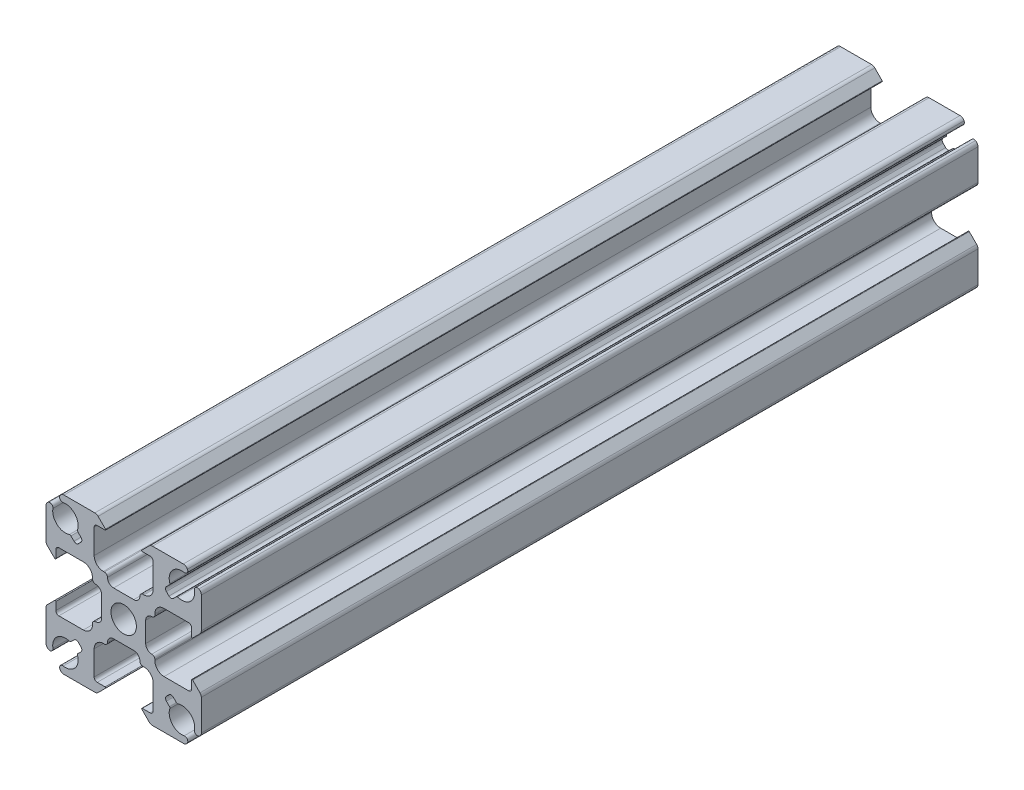
from build123d import *

# Parameters (mm, degrees)
SKETCH1_R           = 2.08
BOSS_EXTRUDE1_DEPTH = 63.5
SKETCH3_W           = 2.5
SKETCH3_H           = 16.3


with BuildPart() as part:
    # Sketch1 → Boss-Extrude1 (new body, symmetric)
    with BuildSketch(Plane(origin=(0, 0, 0), x_dir=(-1, 0, 0), z_dir=(0, 0, -1))):
        with BuildLine():
            Line((-7.48853247, 8.61990332), (-6.985643798, 8.117014648))
            ThreePointArc((-6.985643798, 8.117014648), (-6.839197188, 7.763461257), (-6.985643798, 7.409907866))
            Line((-6.985643798, 7.409907866), (-7.409907866, 6.985643798))
            ThreePointArc((-7.409907866, 6.985643798), (-7.763461257, 6.839197188), (-8.117014648, 6.985643798))
            Line((-8.117014648, 6.985643798), (-8.61990332, 7.48853247))
            ThreePointArc((-8.61990332, 7.48853247), (-8.738774884, 7.554957329), (-8.874825936, 7.549228331))
            ThreePointArc((-8.874825936, 7.549228331), (-10.889377278, 7.955008076), (-11.572136222, 9.893284252))
            ThreePointArc((-11.572136222, 9.893284252), (-11.766795458, 10.383720777), (-12.292708824, 10.42656157))
            ThreePointArc((-12.292708824, 10.42656157), (-12.590129525, 10.150252615), (-12.7, 9.759440396))
            Line((-12.7, 9.759440396), (-12.7, 4.710660172))
            ThreePointArc((-12.7, 4.710660172), (-12.642909649, 4.423647598), (-12.480330086, 4.180330086))
            Line((-12.480330086, 4.180330086), (-11.270710678, 2.970710678))
            ThreePointArc((-11.270710678, 2.970710678), (-11.161731657, 2.949033403), (-11.1, 3.041421356))
            Line((-11.1, 3.041421356), (-11.1, 4.325))
            ThreePointArc((-11.1, 4.325), (-10.953553391, 4.678553391), (-10.6, 4.825))
            Line((-10.6, 4.825), (-6.6, 4.825))
            ThreePointArc((-6.6, 4.825), (-5.539339828, 4.385660172), (-5.1, 3.325))
            Line((-5.1, 3.325), (-5.1, 3.15))
            ThreePointArc((-5.1, 3.15), (-4.953553391, 2.796446609), (-4.6, 2.65))
            ThreePointArc((-4.6, 2.65), (-3.892893219, 2.357106781), (-3.6, 1.65))
            Line((-3.6, 1.65), (-3.6, -1.65))
            ThreePointArc((-3.6, -1.65), (-3.892893219, -2.357106781), (-4.6, -2.65))
            ThreePointArc((-4.6, -2.65), (-4.953553391, -2.796446609), (-5.1, -3.15))
            Line((-5.1, -3.15), (-5.1, -3.325))
            ThreePointArc((-5.1, -3.325), (-5.539339828, -4.385660172), (-6.6, -4.825))
            Line((-6.6, -4.825), (-10.6, -4.825))
            ThreePointArc((-10.6, -4.825), (-10.953553391, -4.678553391), (-11.1, -4.325))
            Line((-11.1, -4.325), (-11.1, -3.041421356))
            ThreePointArc((-11.1, -3.041421356), (-11.161731657, -2.949033403), (-11.270710678, -2.970710678))
            Line((-11.270710678, -2.970710678), (-12.480330086, -4.180330086))
            ThreePointArc((-12.480330086, -4.180330086), (-12.642909649, -4.423647598), (-12.7, -4.710660172))
            Line((-12.7, -4.710660172), (-12.7, -9.759440396))
            ThreePointArc((-12.7, -9.759440396), (-12.590129525, -10.150252615), (-12.292708824, -10.42656157))
            ThreePointArc((-12.292708824, -10.42656157), (-11.766795458, -10.383720777), (-11.572136222, -9.893284252))
            ThreePointArc((-11.572136222, -9.893284252), (-10.889377278, -7.955008076), (-8.874825936, -7.549228331))
            ThreePointArc((-8.874825936, -7.549228331), (-8.738774884, -7.554957329), (-8.61990332, -7.48853247))
            Line((-8.61990332, -7.48853247), (-8.117014648, -6.985643798))
            ThreePointArc((-8.117014648, -6.985643798), (-7.763461257, -6.839197188), (-7.409907866, -6.985643798))
            Line((-7.409907866, -6.985643798), (-6.985643798, -7.409907866))
            ThreePointArc((-6.985643798, -7.409907866), (-6.839197188, -7.763461257), (-6.985643798, -8.117014648))
            Line((-6.985643798, -8.117014648), (-7.48853247, -8.61990332))
            ThreePointArc((-7.48853247, -8.61990332), (-7.554957329, -8.738774884), (-7.549228331, -8.874825936))
            ThreePointArc((-7.549228331, -8.874825936), (-7.955008076, -10.889377278), (-9.893284252, -11.572136222))
            ThreePointArc((-9.893284252, -11.572136222), (-10.383720777, -11.766795458), (-10.42656157, -12.292708824))
            ThreePointArc((-10.42656157, -12.292708824), (-10.150252615, -12.590129525), (-9.759440396, -12.7))
            Line((-9.759440396, -12.7), (-4.710660172, -12.7))
            ThreePointArc((-4.710660172, -12.7), (-4.423647598, -12.642909649), (-4.180330086, -12.480330086))
            Line((-4.180330086, -12.480330086), (-2.970710678, -11.270710678))
            ThreePointArc((-2.970710678, -11.270710678), (-2.949033403, -11.161731657), (-3.041421356, -11.1))
            Line((-3.041421356, -11.1), (-4.325, -11.1))
            ThreePointArc((-4.325, -11.1), (-4.678553391, -10.953553391), (-4.825, -10.6))
            Line((-4.825, -10.6), (-4.825, -6.6))
            ThreePointArc((-4.825, -6.6), (-4.385660172, -5.539339828), (-3.325, -5.1))
            Line((-3.325, -5.1), (-3.15, -5.1))
            ThreePointArc((-3.15, -5.1), (-2.796446609, -4.953553391), (-2.65, -4.6))
            ThreePointArc((-2.65, -4.6), (-2.357106781, -3.892893219), (-1.65, -3.6))
            Line((-1.65, -3.6), (1.65, -3.6))
            ThreePointArc((1.65, -3.6), (2.357106781, -3.892893219), (2.65, -4.6))
            ThreePointArc((2.65, -4.6), (2.796446609, -4.953553391), (3.15, -5.1))
            Line((3.15, -5.1), (3.325, -5.1))
            ThreePointArc((3.325, -5.1), (4.385660172, -5.539339828), (4.825, -6.6))
            Line((4.825, -6.6), (4.825, -10.6))
            ThreePointArc((4.825, -10.6), (4.678553391, -10.953553391), (4.325, -11.1))
            Line((4.325, -11.1), (3.041421356, -11.1))
            ThreePointArc((3.041421356, -11.1), (2.949033403, -11.161731657), (2.970710678, -11.270710678))
            Line((2.970710678, -11.270710678), (4.180330086, -12.480330086))
            ThreePointArc((4.180330086, -12.480330086), (4.423647598, -12.642909649), (4.710660172, -12.7))
            Line((4.710660172, -12.7), (9.759440396, -12.7))
            ThreePointArc((9.759440396, -12.7), (10.150252615, -12.590129525), (10.42656157, -12.292708824))
            ThreePointArc((10.42656157, -12.292708824), (10.383720777, -11.766795458), (9.893284252, -11.572136222))
            ThreePointArc((9.893284252, -11.572136222), (7.955008076, -10.889377278), (7.549228331, -8.874825936))
            ThreePointArc((7.549228331, -8.874825936), (7.554957329, -8.738774884), (7.48853247, -8.61990332))
            Line((7.48853247, -8.61990332), (6.985643798, -8.117014648))
            ThreePointArc((6.985643798, -8.117014648), (6.839197188, -7.763461257), (6.985643798, -7.409907866))
            Line((6.985643798, -7.409907866), (7.409907866, -6.985643798))
            ThreePointArc((7.409907866, -6.985643798), (7.763461257, -6.839197188), (8.117014648, -6.985643798))
            Line((8.117014648, -6.985643798), (8.61990332, -7.48853247))
            ThreePointArc((8.61990332, -7.48853247), (8.738774884, -7.554957329), (8.874825936, -7.549228331))
            ThreePointArc((8.874825936, -7.549228331), (10.889377278, -7.955008076), (11.572136222, -9.893284252))
            ThreePointArc((11.572136222, -9.893284252), (11.766795458, -10.383720777), (12.292708824, -10.42656157))
            ThreePointArc((12.292708824, -10.42656157), (12.590129525, -10.150252615), (12.7, -9.759440396))
            Line((12.7, -9.759440396), (12.7, -4.710660172))
            ThreePointArc((12.7, -4.710660172), (12.642909649, -4.423647598), (12.480330086, -4.180330086))
            Line((12.480330086, -4.180330086), (11.270710678, -2.970710678))
            ThreePointArc((11.270710678, -2.970710678), (11.161731657, -2.949033403), (11.1, -3.041421356))
            Line((11.1, -3.041421356), (11.1, -4.325))
            ThreePointArc((11.1, -4.325), (10.953553391, -4.678553391), (10.6, -4.825))
            Line((10.6, -4.825), (6.6, -4.825))
            ThreePointArc((6.6, -4.825), (5.539339828, -4.385660172), (5.1, -3.325))
            Line((5.1, -3.325), (5.1, -3.15))
            ThreePointArc((5.1, -3.15), (4.953553391, -2.796446609), (4.6, -2.65))
            ThreePointArc((4.6, -2.65), (3.892893219, -2.357106781), (3.6, -1.65))
            Line((3.6, -1.65), (3.6, 1.65))
            ThreePointArc((3.6, 1.65), (3.892893219, 2.357106781), (4.6, 2.65))
            ThreePointArc((4.6, 2.65), (4.953553391, 2.796446609), (5.1, 3.15))
            Line((5.1, 3.15), (5.1, 3.325))
            ThreePointArc((5.1, 3.325), (5.539339828, 4.385660172), (6.6, 4.825))
            Line((6.6, 4.825), (10.6, 4.825))
            ThreePointArc((10.6, 4.825), (10.953553391, 4.678553391), (11.1, 4.325))
            Line((11.1, 4.325), (11.1, 3.041421356))
            ThreePointArc((11.1, 3.041421356), (11.161731657, 2.949033403), (11.270710678, 2.970710678))
            Line((11.270710678, 2.970710678), (12.480330086, 4.180330086))
            ThreePointArc((12.480330086, 4.180330086), (12.642909649, 4.423647598), (12.7, 4.710660172))
            Line((12.7, 4.710660172), (12.7, 9.759440396))
            ThreePointArc((12.7, 9.759440396), (12.590129525, 10.150252615), (12.292708824, 10.42656157))
            ThreePointArc((12.292708824, 10.42656157), (11.766795458, 10.383720777), (11.572136222, 9.893284252))
            ThreePointArc((11.572136222, 9.893284252), (10.889377278, 7.955008076), (8.874825936, 7.549228331))
            ThreePointArc((8.874825936, 7.549228331), (8.738774884, 7.554957329), (8.61990332, 7.48853247))
            Line((8.61990332, 7.48853247), (8.117014648, 6.985643798))
            ThreePointArc((8.117014648, 6.985643798), (7.763461257, 6.839197188), (7.409907866, 6.985643798))
            Line((7.409907866, 6.985643798), (6.985643798, 7.409907866))
            ThreePointArc((6.985643798, 7.409907866), (6.839197188, 7.763461257), (6.985643798, 8.117014648))
            Line((6.985643798, 8.117014648), (7.48853247, 8.61990332))
            ThreePointArc((7.48853247, 8.61990332), (7.554957329, 8.738774884), (7.549228331, 8.874825936))
            ThreePointArc((7.549228331, 8.874825936), (7.955008076, 10.889377278), (9.893284252, 11.572136222))
            ThreePointArc((9.893284252, 11.572136222), (10.383720777, 11.766795458), (10.42656157, 12.292708824))
            ThreePointArc((10.42656157, 12.292708824), (10.150252615, 12.590129525), (9.759440396, 12.7))
            Line((9.759440396, 12.7), (4.710660172, 12.7))
            ThreePointArc((4.710660172, 12.7), (4.423647598, 12.642909649), (4.180330086, 12.480330086))
            Line((4.180330086, 12.480330086), (2.970710678, 11.270710678))
            ThreePointArc((2.970710678, 11.270710678), (2.949033403, 11.161731657), (3.041421356, 11.1))
            Line((3.041421356, 11.1), (4.325, 11.1))
            ThreePointArc((4.325, 11.1), (4.678553391, 10.953553391), (4.825, 10.6))
            Line((4.825, 10.6), (4.825, 6.6))
            ThreePointArc((4.825, 6.6), (4.385660172, 5.539339828), (3.325, 5.1))
            Line((3.325, 5.1), (3.15, 5.1))
            ThreePointArc((3.15, 5.1), (2.796446609, 4.953553391), (2.65, 4.6))
            ThreePointArc((2.65, 4.6), (2.357106781, 3.892893219), (1.65, 3.6))
            Line((1.65, 3.6), (-1.65, 3.6))
            ThreePointArc((-1.65, 3.6), (-2.357106781, 3.892893219), (-2.65, 4.6))
            ThreePointArc((-2.65, 4.6), (-2.796446609, 4.953553391), (-3.15, 5.1))
            Line((-3.15, 5.1), (-3.325, 5.1))
            ThreePointArc((-3.325, 5.1), (-4.385660172, 5.539339828), (-4.825, 6.6))
            Line((-4.825, 6.6), (-4.825, 10.6))
            ThreePointArc((-4.825, 10.6), (-4.678553391, 10.953553391), (-4.325, 11.1))
            Line((-4.325, 11.1), (-3.041421356, 11.1))
            ThreePointArc((-3.041421356, 11.1), (-2.949033403, 11.161731657), (-2.970710678, 11.270710678))
            Line((-2.970710678, 11.270710678), (-4.180330086, 12.480330086))
            ThreePointArc((-4.180330086, 12.480330086), (-4.423647598, 12.642909649), (-4.710660172, 12.7))
            Line((-4.710660172, 12.7), (-9.759440396, 12.7))
            ThreePointArc((-9.759440396, 12.7), (-10.150252615, 12.590129525), (-10.42656157, 12.292708824))
            ThreePointArc((-10.42656157, 12.292708824), (-10.383720777, 11.766795458), (-9.893284252, 11.572136222))
            ThreePointArc((-9.893284252, 11.572136222), (-7.955008076, 10.889377278), (-7.549228331, 8.874825936))
            ThreePointArc((-7.549228331, 8.874825936), (-7.554957329, 8.738774884), (-7.48853247, 8.61990332))
        make_face()
        Circle(SKETCH1_R, mode=Mode.SUBTRACT)
    extrude(amount=BOSS_EXTRUDE1_DEPTH, both=True)

    # Sketch3 → Tap Drill for M6x1.0 Tap1 (revolve, cut)
    with BuildSketch(Plane(origin=(0, -3.6, 50.8), x_dir=(0, 0, -1), z_dir=(1, 0, 0))):
        with Locations((1.25, 8.15)):
            Rectangle(SKETCH3_W, SKETCH3_H)
    revolve(axis=Axis((0, -9.95, 50.8), (0, 1, 0)), mode=Mode.SUBTRACT)


solid = part.part
